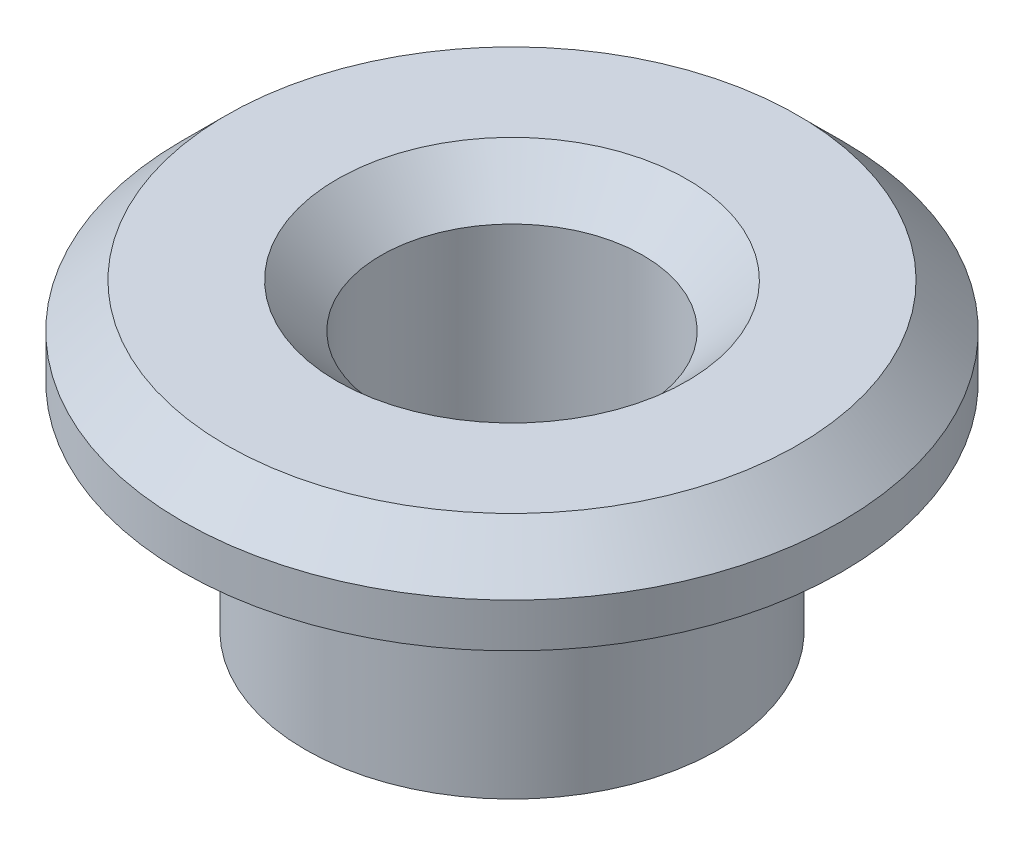
from build123d import *

# Parameters (mm, degrees)
SKETCH1_R           = 4.7
BOSS_EXTRUDE1_DEPTH = 4.9
SKETCH2_R           = 7.5
BOSS_EXTRUDE2_DEPTH = 2
SKETCH3_R           = 2.98
CUT_EXTRUDE1_DEPTH  = 7.9
CHAMFER1_SIZE       = 1
CHAMFER2_SIZE       = 1


with BuildPart() as part:
    # Sketch1 → Boss-Extrude1 (new body)
    with BuildSketch(Plane(origin=(0, 0, 0), x_dir=(1, 0, 0), z_dir=(0, 1, 0))):
        Circle(SKETCH1_R)
    extrude(amount=BOSS_EXTRUDE1_DEPTH)

    # Sketch2 → Boss-Extrude2 (add)
    with BuildSketch(Plane(origin=(0, 4.9, 0), x_dir=(1, 0, 0), z_dir=(0, 1, 0))):
        Circle(SKETCH2_R)
    extrude(amount=BOSS_EXTRUDE2_DEPTH)

    # Sketch3 → Cut-Extrude1 (cut, through all)
    with BuildSketch(Plane(origin=(0, 6.9, 0), x_dir=(1, 0, 0), z_dir=(0, 1, 0))):
        Circle(SKETCH3_R)
    extrude(amount=-CUT_EXTRUDE1_DEPTH, mode=Mode.SUBTRACT)

    # Chamfer1
    chamfer1_edges = [part.edges().sort_by_distance(p)[0] for p in [
        (-2.98, 6.9, 0),
    ]]
    chamfer(chamfer1_edges, length=CHAMFER1_SIZE)

    # Chamfer2
    chamfer2_edges = [part.edges().sort_by_distance(p)[0] for p in [
        (-7.5, 6.9, 0),
    ]]
    chamfer(chamfer2_edges, length=CHAMFER2_SIZE)


solid = part.part
